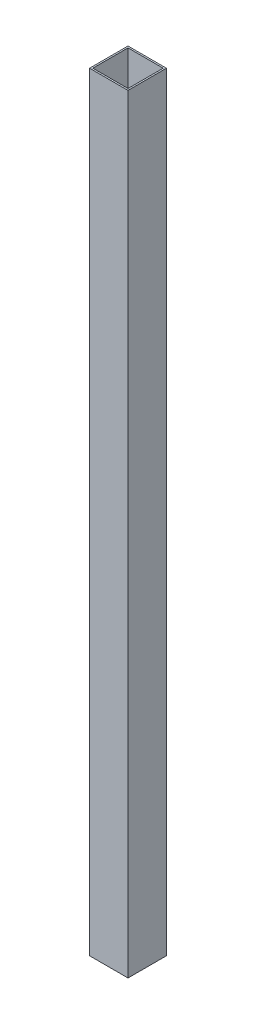
from build123d import *

# Parameters (mm, degrees)
SKETCH1_W           = 38.1
SKETCH1_H           = 38.1
SKETCH1_W_2         = 34.8996
SKETCH1_H_2         = 34.8996
BOSS_EXTRUDE1_DEPTH = 762


with BuildPart() as part:
    # Sketch1 → Boss-Extrude1 (new body)
    with BuildSketch(Plane(origin=(0, 0, 0), x_dir=(1, 0, 0), z_dir=(0, 1, 0))):
        with Locations((19.05, 19.05)):
            Rectangle(SKETCH1_W, SKETCH1_H)
        with Locations((19.05, 19.05)):
            Rectangle(SKETCH1_W_2, SKETCH1_H_2, mode=Mode.SUBTRACT)
    extrude(amount=BOSS_EXTRUDE1_DEPTH)


solid = part.part
